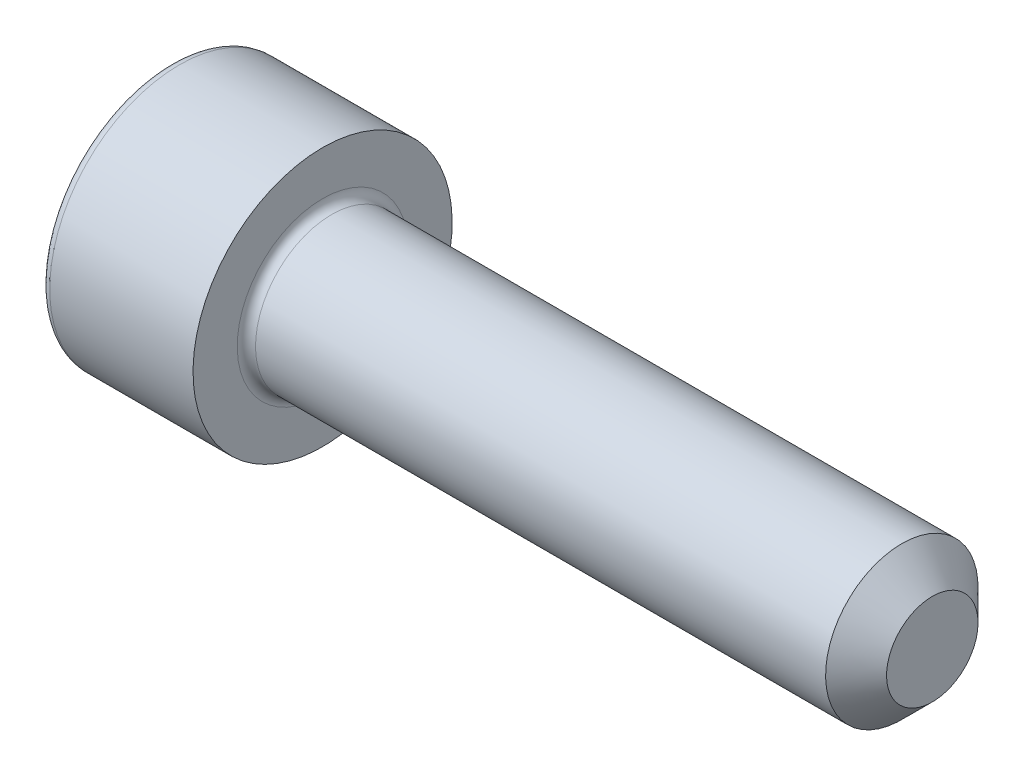
from build123d import *

# Parameters (mm, degrees)
CUT_EXTRUDE_1_DEPTH = 2.5
FILLET_1_R          = 0.3
CHAMFER_1_SIZE      = 1


with BuildPart() as part:
    # Эскиз1 → Повернуть1 (revolve)
    with BuildSketch(Plane.XY):
        Polygon((0, 0), (0, 4.25), (5, 4.25), (5, 2.5), (25, 2.5), (25, 0), align=None)
    revolve(axis=Axis((25, 0, 0), (-1, 0, 0)))

    # Эскиз2 → Вырез-Вытянуть1 (cut)
    with BuildSketch(Plane.ZY):
        Polygon((-1.154700538, 2), (-2.309401077, 0), (-1.154700538, -2), (1.154700538, -2), (2.309401077, 0), (1.154700538, 2), align=None)
    extrude(amount=-CUT_EXTRUDE_1_DEPTH, mode=Mode.SUBTRACT)

    # Скругление1
    fillet_1_edges = [part.edges().sort_by_distance(p)[0] for p in [
        (5, -2.5, 0),
        (0, -4.25, 0),
    ]]
    fillet(fillet_1_edges, radius=FILLET_1_R)

    # Фаска1
    chamfer_1_edges = [part.edges().sort_by_distance(p)[0] for p in [
        (25, -2.5, 0),
    ]]
    chamfer(chamfer_1_edges, length=CHAMFER_1_SIZE)


solid = part.part
